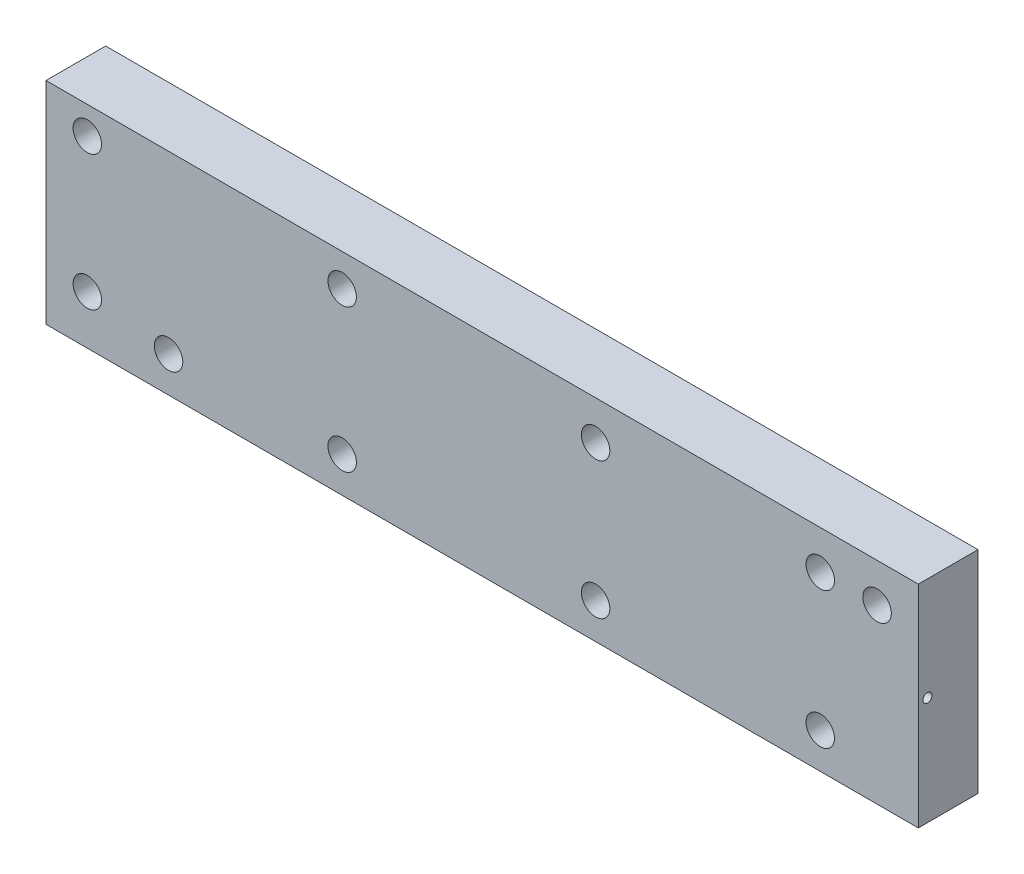
from build123d import *

# Parameters (mm, degrees)
SKIZZE2_W                                  = 120
SKIZZE2_H                                  = 40
AUFSATZ_LINEAR_AUSTRAGEN1_DEPTH            = 30
SKIZZE80_R                                 = 0.5
SCHNITT_LINEAR_AUSTRAGEN34_DEPTH           = 21.05
SCHNITT_LINEAR_START                       = -9
SKIZZE81_R                                 = 0.5
SCHNITT_LINEAR_AUSTRAGEN36_DEPTH           = 5
SKIZZE89_R                                 = 0.75
SCHNITT_LINEAR_AUSTRAGEN37_DEPTH           = 19
SKIZZE89_3_R                               = 2.1
SKIZZE89_3_R_2                             = 0.75
SCHNITT_LINEAR_AUSTRAGEN38_DEPTH           = 12
FASE1_SIZE                                 = 1.3
F_3_1_3_1_DURCHMESSER_BOHRUNG1_D           = 3.1
F_3_1_3_1_DURCHMESSER_BOHRUNG1_CSINK_D     = 3.15
F_3_1_3_1_DURCHMESSER_BOHRUNG1_CSINK_ANGLE = 90
SKIZZE83_W                                 = 8.5
SKIZZE83_H                                 = 23
SKIZZE83_W_2                               = 7
SCHNITT_LINEAR_AUSTRAGEN39_DEPTH           = 135
SKIZZE93_W                                 = 12.5
SKIZZE93_H                                 = 14.5
SCHNITT_LINEAR_AUSTRAGEN40_DEPTH           = 135
ABSPALTEN1_SURFACE_1_BACK                  = 99.814
ABSPALTEN1_SURFACE_1_DEPTH                 = 199.628


with BuildPart() as part:
    # Skizze2 → Aufsatz-Linear austragen1 (new body)
    with BuildSketch(Plane.XY):
        with Locations((60, 20)):
            Rectangle(SKIZZE2_W, SKIZZE2_H)
    extrude(amount=AUFSATZ_LINEAR_AUSTRAGEN1_DEPTH)

    # Skizze80 → Schnitt-Linear austragen34 (cut)
    with BuildSketch(Plane(origin=(120, 0, 0), x_dir=(0, 0, -1), z_dir=(1, 0, 0))):
        with Locations((-20.502569313, 19.779069372)):
            Circle(SKIZZE80_R)
    schnitt_linear_austragen34 = extrude(amount=-SCHNITT_LINEAR_AUSTRAGEN34_DEPTH, mode=Mode.SUBTRACT)

    # Skizze81 → Schnitt-Linear austragen36 (cut)
    with BuildSketch(Plane.XY.offset(30).offset(SCHNITT_LINEAR_START)):
        with Locations((99, 20)):
            Circle(SKIZZE81_R)
    schnitt_linear_austragen36 = extrude(amount=-SCHNITT_LINEAR_AUSTRAGEN36_DEPTH, mode=Mode.SUBTRACT)

    # Spiegeln4: Schnitt-Linear austragen34, Schnitt-Linear austragen36 across plane
    add(schnitt_linear_austragen34.mirror(Plane.XY.offset(15)), mode=Mode.SUBTRACT)
    add(schnitt_linear_austragen36.mirror(Plane.XY.offset(15)), mode=Mode.SUBTRACT)

    # Skizze89 → Schnitt-Linear austragen37 (cut)
    with BuildSketch(Plane.XZ):
        with Locations(Location((20.75, 10.195, 0), (0, 0, 270))):
            Circle(SKIZZE89_R)
    extrude(amount=-SCHNITT_LINEAR_AUSTRAGEN37_DEPTH, mode=Mode.SUBTRACT)

    # Skizze89_3 → Schnitt-Linear austragen38 (cut)
    with BuildSketch(Plane.XZ):
        with Locations(Location((20.75, 10.195, 0), (0, 0, 270))):
            Circle(SKIZZE89_3_R)
        with Locations(Location((20.75, 10.195, 0), (0, 0, 270))):
            Circle(SKIZZE89_3_R_2, mode=Mode.SUBTRACT)
    extrude(amount=-SCHNITT_LINEAR_AUSTRAGEN38_DEPTH, mode=Mode.SUBTRACT)

    # Fase1
    fase1_edges = [part.edges().sort_by_distance(p)[0] for p in [
        (20.75, 12, 10.945),
    ]]
    chamfer(fase1_edges, length=FASE1_SIZE)

    # 3.1 _3.1_ Durchmesser Bohrung1 (through all)
    with Locations(Plane(origin=(0, 0, 0), x_dir=(-1, 0, 0), z_dir=(0, 0, -1))):
        with Locations((-17, 28), (-44.752782077, 27.472603229), (-72.354196867, 26.76756786), (-96.819713549, 26.76756786), (-103.008357344, 26.76756786), (-17, 13.319343937), (-25.846153065, 11.883487847), (-44.752782077, 11.883487847), (-72.354196867, 11.883487847), (-96.819713549, 11.883487847)):
            CounterSinkHole(F_3_1_3_1_DURCHMESSER_BOHRUNG1_D / 2, F_3_1_3_1_DURCHMESSER_BOHRUNG1_CSINK_D / 2, counter_sink_angle=F_3_1_3_1_DURCHMESSER_BOHRUNG1_CSINK_ANGLE)

    # Skizze83 → Schnitt-Linear austragen39 (cut)
    with BuildSketch(Plane.ZY):
        with Locations((25.75, 19.5)):
            Rectangle(SKIZZE83_W, SKIZZE83_H)
        Polygon((30, 0), (30, 8), (21.5, 8), (7, 8), (0, 8), (0, 0), align=None)
        with Locations((3.5, 19.5)):
            Rectangle(SKIZZE83_W_2, SKIZZE83_H)
        Polygon((21.5, 31), (30, 31), (30, 40), (0, 40), (0, 31), (7, 31), align=None)
    extrude(amount=-SCHNITT_LINEAR_AUSTRAGEN39_DEPTH, mode=Mode.SUBTRACT)

    # Skizze93 → Schnitt-Linear austragen40 (cut)
    with BuildSketch(Plane(origin=(0, 31, 0), x_dir=(1, 0, 0), z_dir=(0, 1, 0))):
        with Locations((113.75, -14.25)):
            Rectangle(SKIZZE93_W, SKIZZE93_H)
        with Locations((6.25, -14.25)):
            Rectangle(SKIZZE93_W, SKIZZE93_H)
    extrude(amount=-SCHNITT_LINEAR_AUSTRAGEN40_DEPTH, mode=Mode.SUBTRACT)

    # Skizze99 → Schnitt-Rotation2 (revolve, cut)
    with BuildSketch(Plane.XY.offset(15), mode=Mode.PRIVATE) as schnitt_rotation2_sk:
        Polygon((14.5, 19.495348829), (14.5, 23.595348829), (20, 23.595348829), (20, 25.095348829), (100, 23.383720543), (100, 21.883720543), (105.5, 21.883720543), (105.5, 19.283720543), align=None)
    revolve(schnitt_rotation2_sk.sketch.rotate(Axis((12.5, 19.5, 15), (0.9999972958368729, -0.0023255792701378343, 0)), 180), axis=Axis((12.5, 19.5, 15), (0.9999972958368729, -0.0023255792701378343, 0)), mode=Mode.SUBTRACT)

    # Abspalten1: cut with a surface, the side behind it stays
    # Abspalten1 surface: a surface, the sketch's curves swept straight by 199.628 mm
    with BuildLine(Plane(origin=(107.5, 0, 0), x_dir=(0, 0, -1), z_dir=(1, 0, 0)).offset(-ABSPALTEN1_SURFACE_1_BACK), mode=Mode.PRIVATE) as abspalten1_surface_1_path:
        Line((-15, 31), (-15, 8))
    abspalten1_surface_1 = Shell.extrude(abspalten1_surface_1_path.wire(), (1 * ABSPALTEN1_SURFACE_1_DEPTH, 0 * ABSPALTEN1_SURFACE_1_DEPTH, 0 * ABSPALTEN1_SURFACE_1_DEPTH))
    split(bisect_by=abspalten1_surface_1, keep=Keep.BOTTOM)


solid = part.part
